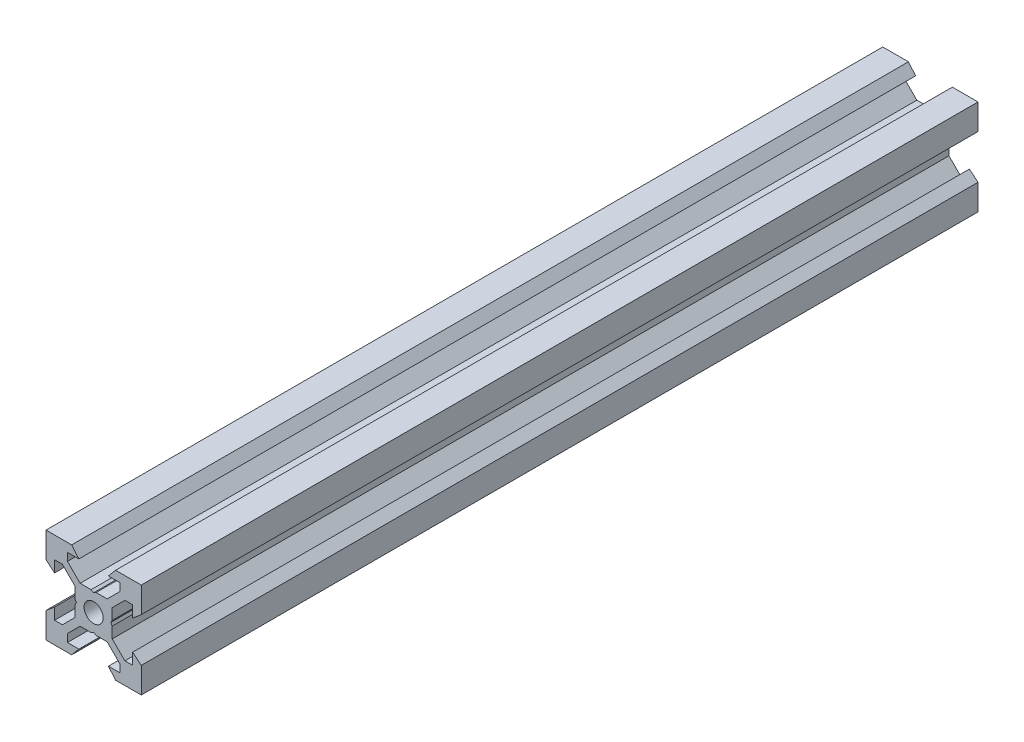
from build123d import *

# Parameters (mm, degrees)
SKETCH1_R           = 2
BOSS_EXTRUDE1_DEPTH = 87.845


with BuildPart() as part:
    # Sketch1 → Boss-Extrude1 (new body, symmetric)
    with BuildSketch(Plane.XY):
        Polygon((10, 10), (10, 4.610379336), (8.2, 3.1), (8.2, 5.5), (6.560660172, 5.5), (3.9, 2.839339828), (3.9, 0.519615242), (3.6, 0), (3.9, -0.519615242), (3.9, -2.839339828), (6.560660172, -5.5), (8.2, -5.5), (8.2, -3.1), (10, -4.610379336), (10, -10), (4.610379336, -10), (3.1, -8.2), (5.5, -8.2), (5.5, -6.560660172), (2.839339828, -3.9), (0.519615242, -3.9), (0, -3.6), (-0.519615242, -3.9), (-2.839339828, -3.9), (-5.5, -6.560660172), (-5.5, -8.2), (-3.1, -8.2), (-4.610379336, -10), (-10, -10), (-10, -4.610379336), (-8.2, -3.1), (-8.2, -5.5), (-6.560660172, -5.5), (-3.9, -2.839339828), (-3.9, -0.519615242), (-3.6, 0), (-3.9, 0.519615242), (-3.9, 2.839339828), (-6.560660172, 5.5), (-8.2, 5.5), (-8.2, 3.1), (-10, 4.610379336), (-10, 10), (-4.610379336, 10), (-3.1, 8.2), (-5.5, 8.2), (-5.5, 6.560660172), (-2.839339828, 3.9), (-0.519615242, 3.9), (0, 3.6), (0.519615242, 3.9), (2.839339828, 3.9), (5.5, 6.560660172), (5.5, 8.2), (3.1, 8.2), (4.610379336, 10), align=None)
        Circle(SKETCH1_R, mode=Mode.SUBTRACT)
    extrude(amount=BOSS_EXTRUDE1_DEPTH, both=True)


solid = part.part
